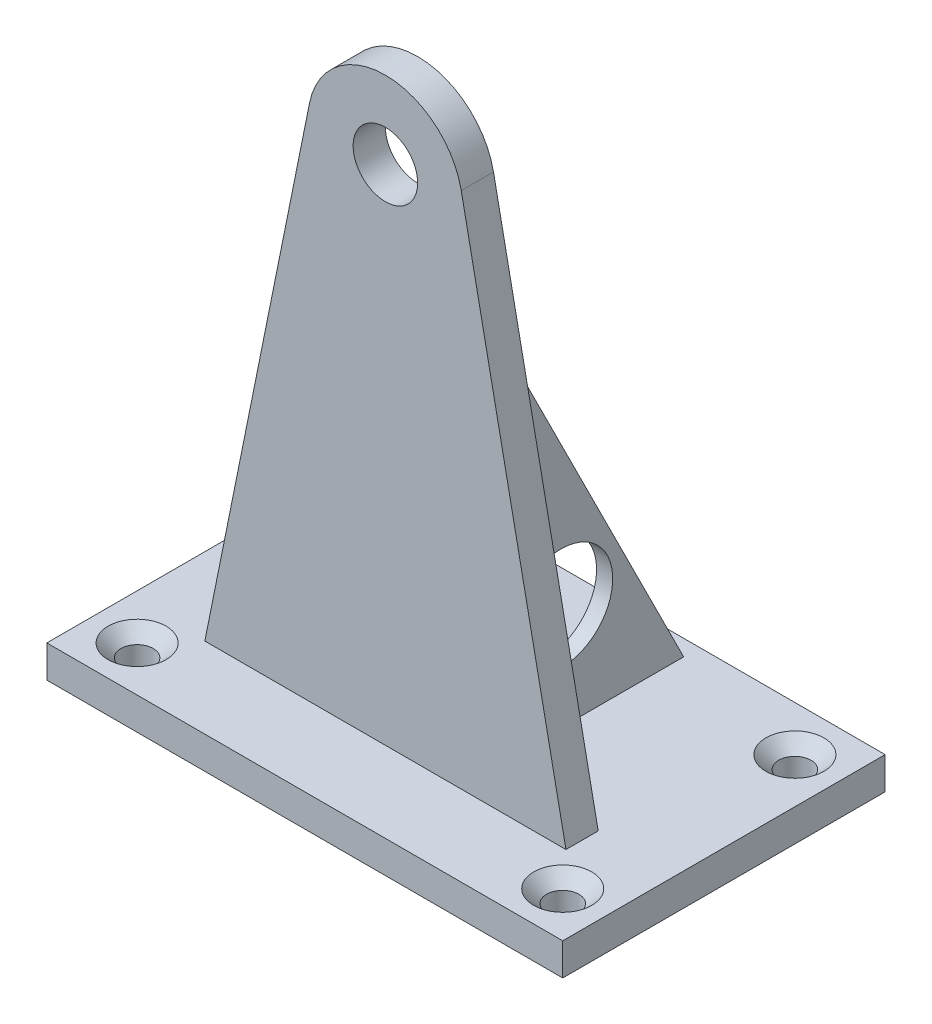
from build123d import *

# Parameters (mm, degrees)
SKETCH2_W           = 80
SKETCH2_H           = 50
BOSS_EXTRUDE1_DEPTH = 5
BOSS_EXTRUDE2_DEPTH = 2.5
RIB1_REACH          = 112.227
SKETCH6_WALL_W      = 289.536116176
SKETCH6_WALL_H      = 2.5
SKETCH7_R           = 8
CUT_EXTRUDE1_DEPTH  = 2.5
SKETCH3_R           = 2.5
CUT_EXTRUDE2_DEPTH  = 5
CHAMFER1_SIZE       = 2
SKETCH8_R           = 5
CUT_EXTRUDE3_DEPTH  = 2.5


with BuildPart() as part:
    # Sketch2 → Boss-Extrude1 (new body)
    with BuildSketch(Plane(origin=(0, 0, 0), x_dir=(1, 0, 0), z_dir=(0, 1, 0))):
        Rectangle(SKETCH2_W, SKETCH2_H)
    extrude(amount=BOSS_EXTRUDE1_DEPTH)

    # Sketch4 → Boss-Extrude2 (add, symmetric)
    with BuildSketch(Plane.XY.offset(10)):
        with BuildLine():
            Line((0, 5), (-28, 5))
            Line((-28, 5), (-11.762376238, 85.376237624))
            ThreePointArc((-11.762376238, 85.376237624), (-7.598853483, 92.28748759), (0, 95))
            Line((0, 95), (0, 83))
            Line((0, 83), (0, 5))
        make_face()
    boss_extrude2 = extrude(amount=BOSS_EXTRUDE2_DEPTH, both=True)

    # Sketch6 wall → Rib1 (add, up to next)
    with BuildSketch(Plane(origin=(-10, 35, -7.5), x_dir=(0, -0.894427191, -0.4472135955), z_dir=(0, 0.4472135955, -0.894427191)), mode=Mode.PRIVATE) as rib1_sk1:
        Rectangle(SKETCH6_WALL_W, SKETCH6_WALL_H)
    rib1_tool1 = extrude(rib1_sk1.sketch, amount=-RIB1_REACH, mode=Mode.PRIVATE) - part.part
    rib1 = rib1_tool1.solids().sort_by_distance((-10, 35, -7.5))[0]
    add(rib1)

    # Sketch7 → Cut-Extrude1 (cut, symmetric)
    with BuildSketch(Plane(origin=(-10, 0, 0), x_dir=(0, 0, -1), z_dir=(1, 0, 0))):
        with Locations((3.5, 21)):
            Circle(SKETCH7_R)
    cut_extrude1 = extrude(amount=CUT_EXTRUDE1_DEPTH, both=True, mode=Mode.SUBTRACT)

    # Mirror2: Boss-Extrude2, Rib1, Cut-Extrude1 across plane
    add(boss_extrude2.mirror(Plane(origin=(0, 83, 7.5), x_dir=(0, 0, 1), z_dir=(1, 0, 0))))
    add(rib1.mirror(Plane(origin=(0, 83, 7.5), x_dir=(0, 0, 1), z_dir=(1, 0, 0))))
    add(cut_extrude1.mirror(Plane(origin=(0, 83, 7.5), x_dir=(0, 0, 1), z_dir=(1, 0, 0))), mode=Mode.SUBTRACT)

    # Sketch3 → Cut-Extrude2 (cut)
    with BuildSketch(Plane(origin=(0, 5, 0), x_dir=(1, 0, 0), z_dir=(0, 1, 0))):
        with Locations(Location((-33, 18, 0), (0, 0, 270))):
            Circle(SKETCH3_R)
        with Locations(Location((-33, -18, 0), (0, 0, 90))):
            Circle(SKETCH3_R)
        with Locations(Location((33, -18, 0), (0, 0, 270))):
            Circle(SKETCH3_R)
        with Locations(Location((33, 18, 0), (0, 0, 90))):
            Circle(SKETCH3_R)
    extrude(amount=-CUT_EXTRUDE2_DEPTH, mode=Mode.SUBTRACT)

    # Chamfer1
    chamfer1_edges = [part.edges().sort_by_distance(p)[0] for p in [
        (33, 5, -15.5),
        (33, 5, 15.5),
        (-33, 5, 20.5),
        (-33, 5, -20.5),
    ]]
    chamfer(chamfer1_edges, length=CHAMFER1_SIZE)

    # Sketch8 → Cut-Extrude3 (cut, symmetric)
    with BuildSketch(Plane.XY.offset(10)):
        with Locations((0, 83)):
            Circle(SKETCH8_R)
    extrude(amount=CUT_EXTRUDE3_DEPTH, both=True, mode=Mode.SUBTRACT)


solid = part.part
